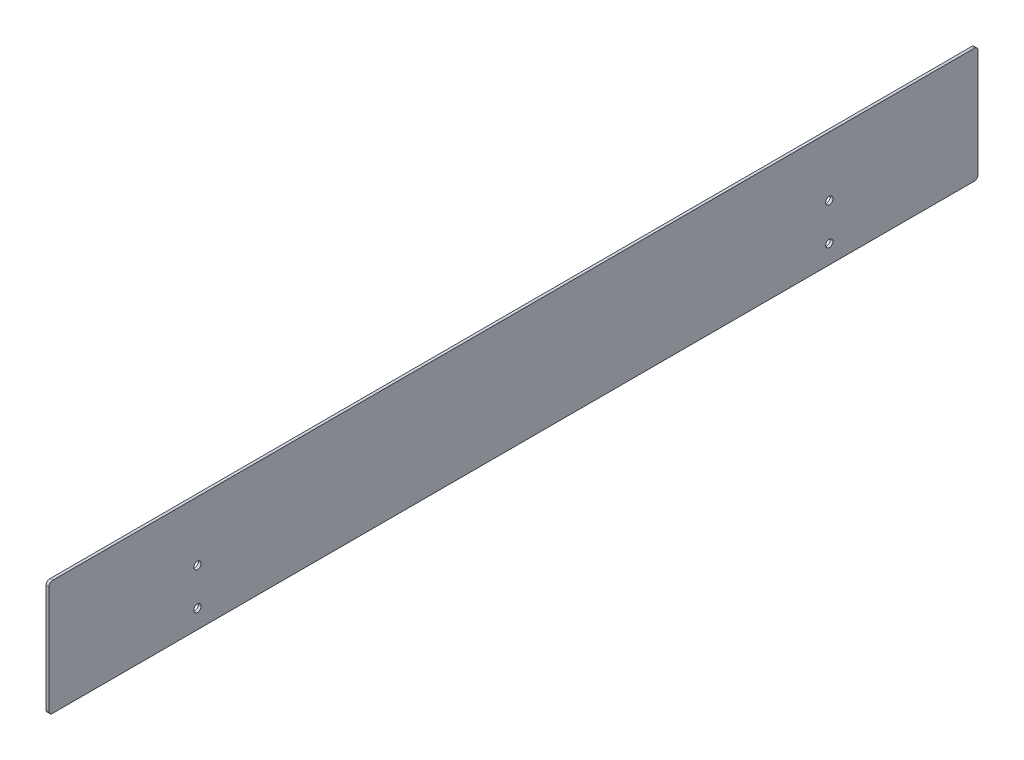
from build123d import *

# Parameters (mm, degrees)
SKETCH1_W           = 500
SKETCH1_H           = 62
SKETCH1_R           = 1.95
BOSS_EXTRUDE1_DEPTH = 1.5
FILLET1_R           = 2


with BuildPart() as part:
    # Sketch1 → Boss-Extrude1 (new body)
    with BuildSketch(Plane(origin=(0, 0, 0), x_dir=(0, 0, -1), z_dir=(1, 0, 0))):
        with Locations((-11.339345362, -109.292553191)):
            Rectangle(SKETCH1_W, SKETCH1_H)
        with Locations((158.660654638, -110.292553191)):
            Circle(SKETCH1_R, mode=Mode.SUBTRACT)
        with Locations((158.660654638, -130.292553191)):
            Circle(SKETCH1_R, mode=Mode.SUBTRACT)
        with Locations((-181.339345362, -110.292553191)):
            Circle(SKETCH1_R, mode=Mode.SUBTRACT)
        with Locations((-181.339345362, -130.292553191)):
            Circle(SKETCH1_R, mode=Mode.SUBTRACT)
    extrude(amount=BOSS_EXTRUDE1_DEPTH)

    # Fillet1
    fillet1_edges = [part.edges().sort_by_distance(p)[0] for p in [
        (0.75, -78.292553191, 261.339345362),
        (0.75, -78.292553191, -238.660654638),
        (0.75, -140.292553191, -238.660654638),
        (0.75, -140.292553191, 261.339345362),
    ]]
    fillet(fillet1_edges, radius=FILLET1_R)


solid = part.part
